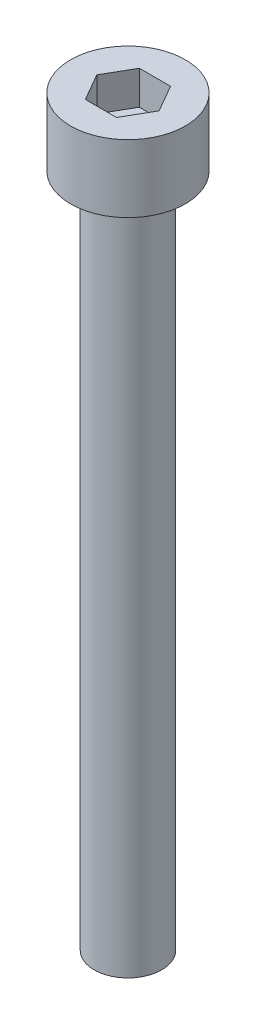
from build123d import *

# Parameters (mm, degrees)
SKETCH_1_R          = 4.25
EXTRUDE_1_DEPTH     = 5
CUT_EXTRUDE_1_DEPTH = 2.5
SKETCH_3_R          = 2.5
EXTRUDE_2_DEPTH     = 50


with BuildPart() as part:
    # 草图1 → 凸台-拉伸1 (new body)
    with BuildSketch(Plane(origin=(0, 0, 0), x_dir=(1, 0, 0), z_dir=(0, 1, 0))):
        Circle(SKETCH_1_R)
    extrude(amount=EXTRUDE_1_DEPTH)

    # 草图2 → 切除-拉伸1 (cut)
    with BuildSketch(Plane(origin=(0, 5, 0), x_dir=(1, 0, 0), z_dir=(0, 1, 0))):
        Polygon((2.309401077, 0), (1.154700538, 2), (-1.154700538, 2), (-2.309401077, 0), (-1.154700538, -2), (1.154700538, -2), align=None)
    extrude(amount=-CUT_EXTRUDE_1_DEPTH, mode=Mode.SUBTRACT)

    # 草图3 → 凸台-拉伸2 (add)
    with BuildSketch(Plane.XZ):
        Circle(SKETCH_3_R)
    extrude(amount=EXTRUDE_2_DEPTH)


solid = part.part
